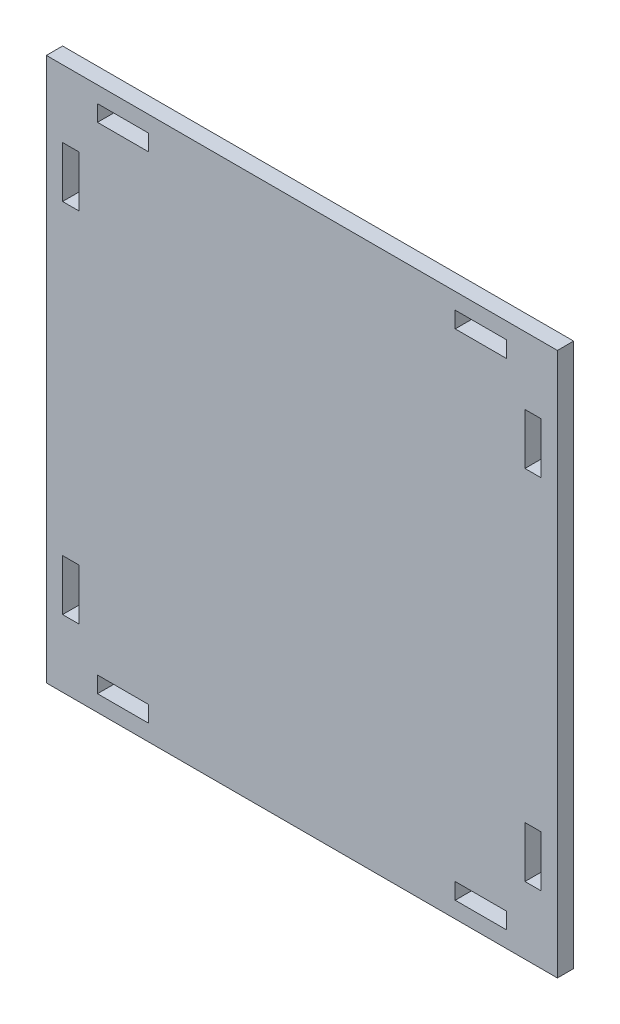
from build123d import *

# Parameters (mm, degrees)
SKETCH1_W           = 100
SKETCH1_H           = 106.35
SKETCH1_W_2         = 3.175
SKETCH1_H_2         = 10
SKETCH1_W_3         = 10
SKETCH1_H_3         = 3.175
BOSS_EXTRUDE1_DEPTH = 3.175


with BuildPart() as part:
    # Sketch1 → Boss-Extrude1 (new body)
    with BuildSketch(Plane.XY):
        with Locations((50, 53.175)):
            Rectangle(SKETCH1_W, SKETCH1_H)
        with Locations((4.7625, 88.175)):
            Rectangle(SKETCH1_W_2, SKETCH1_H_2, mode=Mode.SUBTRACT)
        with Locations((15, 101.5875)):
            Rectangle(SKETCH1_W_3, SKETCH1_H_3, mode=Mode.SUBTRACT)
        with Locations((85, 101.5875)):
            Rectangle(SKETCH1_W_3, SKETCH1_H_3, mode=Mode.SUBTRACT)
        with Locations((95.2375, 88.175)):
            Rectangle(SKETCH1_W_2, SKETCH1_H_2, mode=Mode.SUBTRACT)
        with Locations((95.2375, 18.175)):
            Rectangle(SKETCH1_W_2, SKETCH1_H_2, mode=Mode.SUBTRACT)
        with Locations((85, 4.7625)):
            Rectangle(SKETCH1_W_3, SKETCH1_H_3, mode=Mode.SUBTRACT)
        with Locations((15, 4.7625)):
            Rectangle(SKETCH1_W_3, SKETCH1_H_3, mode=Mode.SUBTRACT)
        with Locations((4.7625, 18.175)):
            Rectangle(SKETCH1_W_2, SKETCH1_H_2, mode=Mode.SUBTRACT)
    extrude(amount=BOSS_EXTRUDE1_DEPTH)


solid = part.part
